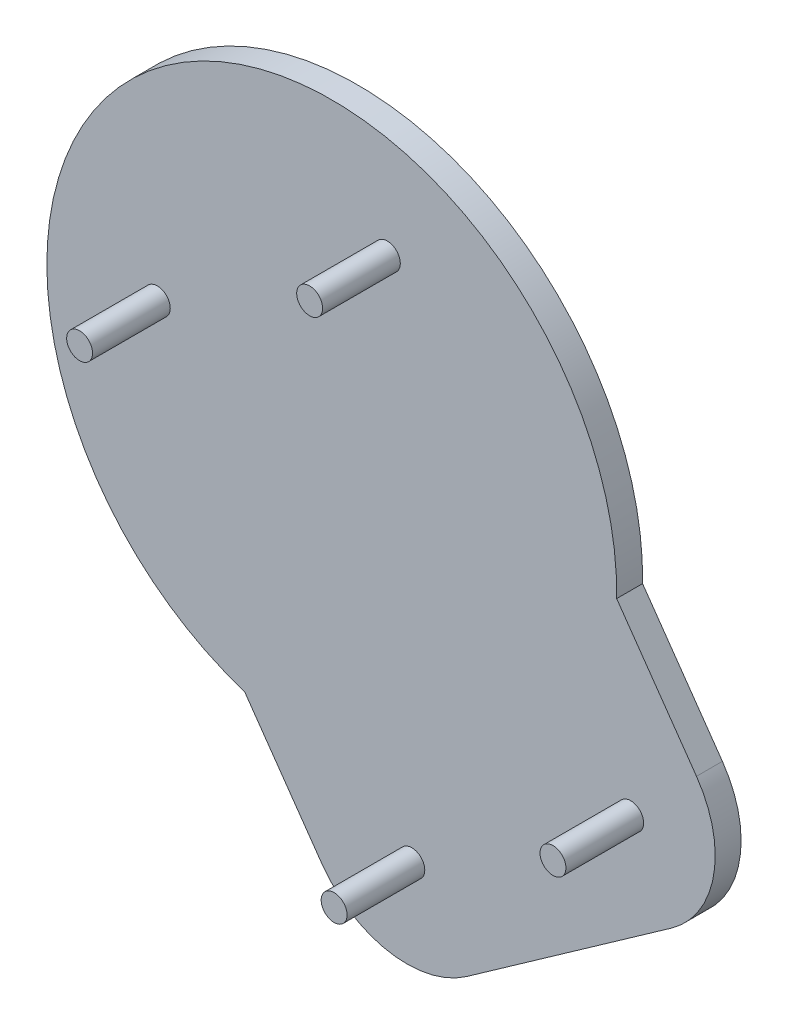
from build123d import *

# Parameters (mm, degrees)
SKETCH1_R             = 2.5
BOSS_EXTRUDE1_DEPTH   = 5
SKETCH3_R             = 2.5
BOSS_EXTRUDE2_DEPTH   = 15
BOSS_EXTRUDE2_2_DEPTH = 15
BOSS_EXTRUDE2_3_DEPTH = 15
BOSS_EXTRUDE2_4_DEPTH = 15


with BuildPart() as part:
    # Sketch1 → Boss-Extrude1 (new body)
    with BuildSketch(Plane.XY):
        with BuildLine():
            Line((-57.672811588, -5.12960821), (-42.735681757, -26.462040404))
            ThreePointArc((-42.735681757, -26.462040404), (-29.796444215, -34.691786217), (-14.832658533, -31.339517974))
            Line((-14.832658533, -31.339517974), (24.696261992, -3.486298151))
            ThreePointArc((24.696261992, -3.486298151), (32.877554195, 9.418904803), (29.55932054, 24.334236874))
            Line((29.55932054, 24.334236874), (14.152654619, 46.337236099))
            ThreePointArc((14.152654619, 46.337236099), (-72.875300714, 91.93856773), (-57.672811588, -5.12960821))
        make_face()
        with Locations((16.857134213, 11.403652355)):
            Circle(SKETCH1_R, mode=Mode.SUBTRACT)
        with Locations((-25.390539185, -17.583455648)):
            Circle(SKETCH1_R, mode=Mode.SUBTRACT)
        with Locations((-74.51852092, 51.77499716)):
            Circle(SKETCH1_R, mode=Mode.SUBTRACT)
        with Locations((-30.115539643, 81.478943582)):
            Circle(SKETCH1_R, mode=Mode.SUBTRACT)
    extrude(amount=BOSS_EXTRUDE1_DEPTH)


with BuildPart() as body_2:
    # Sketch3 → Boss-Extrude2 (new body)
    with BuildSketch(Plane.XY.offset(5)):
        with Locations((16.857134213, 11.403652355)):
            Circle(SKETCH3_R)
    extrude(amount=BOSS_EXTRUDE2_DEPTH)


with BuildPart() as body_3:
    # Sketch3 → Boss-Extrude2 2 (new body)
    with BuildSketch(Plane.XY.offset(5)):
        with Locations((-25.390539185, -17.583455648)):
            Circle(SKETCH3_R)
    extrude(amount=BOSS_EXTRUDE2_2_DEPTH)


with BuildPart() as body_4:
    # Sketch3 → Boss-Extrude2 3 (new body)
    with BuildSketch(Plane.XY.offset(5)):
        with Locations((-30.115539643, 81.478943582)):
            Circle(SKETCH3_R)
    extrude(amount=BOSS_EXTRUDE2_3_DEPTH)


with BuildPart() as body_5:
    # Sketch3 → Boss-Extrude2 4 (new body)
    with BuildSketch(Plane.XY.offset(5)):
        with Locations((-74.51852092, 51.77499716)):
            Circle(SKETCH3_R)
    extrude(amount=BOSS_EXTRUDE2_4_DEPTH)


solid = Compound([part.part, body_2.part, body_3.part, body_4.part, body_5.part])
